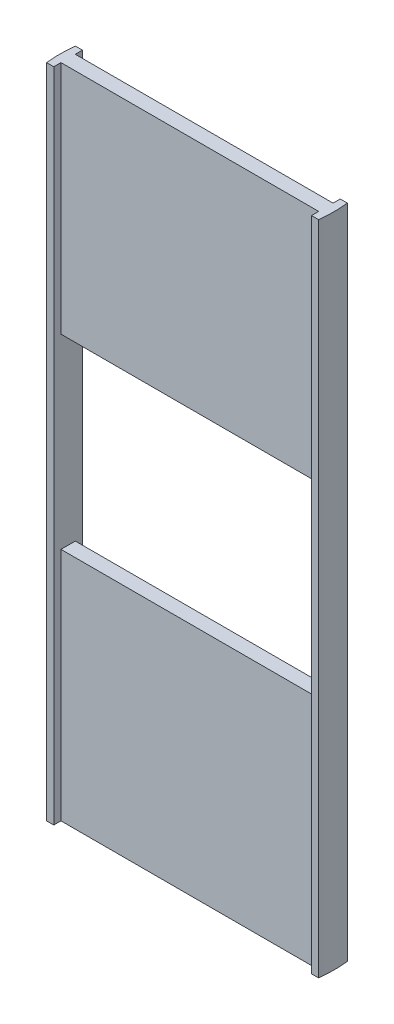
from build123d import *

# Parameters (mm, degrees)
SKETCH1_R               = 95.25
BOSS_EXTRUDE1_DEPTH     = 457.2
CUT_EXTRUDE1_DEPTH      = 457.2
CUT_EXTRUDE2_DEPTH      = 457.2
SKETCH9_W               = 179.447222202
SKETCH9_H               = 129.77242504
CUT_EXTRUDE4_DEPTH      = 11
CUT_EXTRUDE4_DEPTH_BACK = 11


with BuildPart() as part:
    # Sketch1 → Boss-Extrude1 (new body)
    with BuildSketch(Plane(origin=(0, 0, 0), x_dir=(1, 0, 0), z_dir=(0, 1, 0))):
        Circle(SKETCH1_R)
    extrude(amount=BOSS_EXTRUDE1_DEPTH)

    # Sketch2 → Cut-Extrude1 (cut)
    with BuildSketch(Plane(origin=(0, 457.2, 0), x_dir=(1, 0, 0), z_dir=(0, 1, 0))):
        with BuildLine():
            Line((89.723611101, 10), (89.723611101, 5))
            Line((89.723611101, 5), (-89.723611101, 5))
            Line((-89.723611101, 5), (-89.723611101, 10))
            Line((-89.723611101, 10), (-94.723611101, 10))
            ThreePointArc((-94.723611101, 10), (0, 95.25), (94.723611101, 10))
            Line((94.723611101, 10), (89.723611101, 10))
        make_face()
    extrude(amount=-CUT_EXTRUDE1_DEPTH, mode=Mode.SUBTRACT)

    # Sketch5 → Cut-Extrude2 (cut)
    with BuildSketch(Plane(origin=(0, 457.2, 0), x_dir=(1, 0, 0), z_dir=(0, 1, 0))):
        with BuildLine():
            Line((0, -5), (-89.723611101, -5))
            Line((-89.723611101, -5), (-89.723611101, -10))
            Line((-89.723611101, -10), (-94.723611101, -10))
            ThreePointArc((-94.723611101, -10), (0, -95.25), (94.723611101, -10))
            Line((94.723611101, -10), (89.723611101, -10))
            Line((89.723611101, -10), (89.723611101, -5))
            Line((89.723611101, -5), (0, -5))
        make_face()
    extrude(amount=-CUT_EXTRUDE2_DEPTH, mode=Mode.SUBTRACT)

    # Sketch9 → Cut-Extrude4 (cut, two sides)
    with BuildSketch(Plane.XY) as cut_extrude4_sk:
        with Locations((0, 228.6)):
            Rectangle(SKETCH9_W, SKETCH9_H)
    extrude(amount=CUT_EXTRUDE4_DEPTH, mode=Mode.SUBTRACT)
    extrude(cut_extrude4_sk.sketch, amount=-CUT_EXTRUDE4_DEPTH_BACK, mode=Mode.SUBTRACT)


solid = part.part
